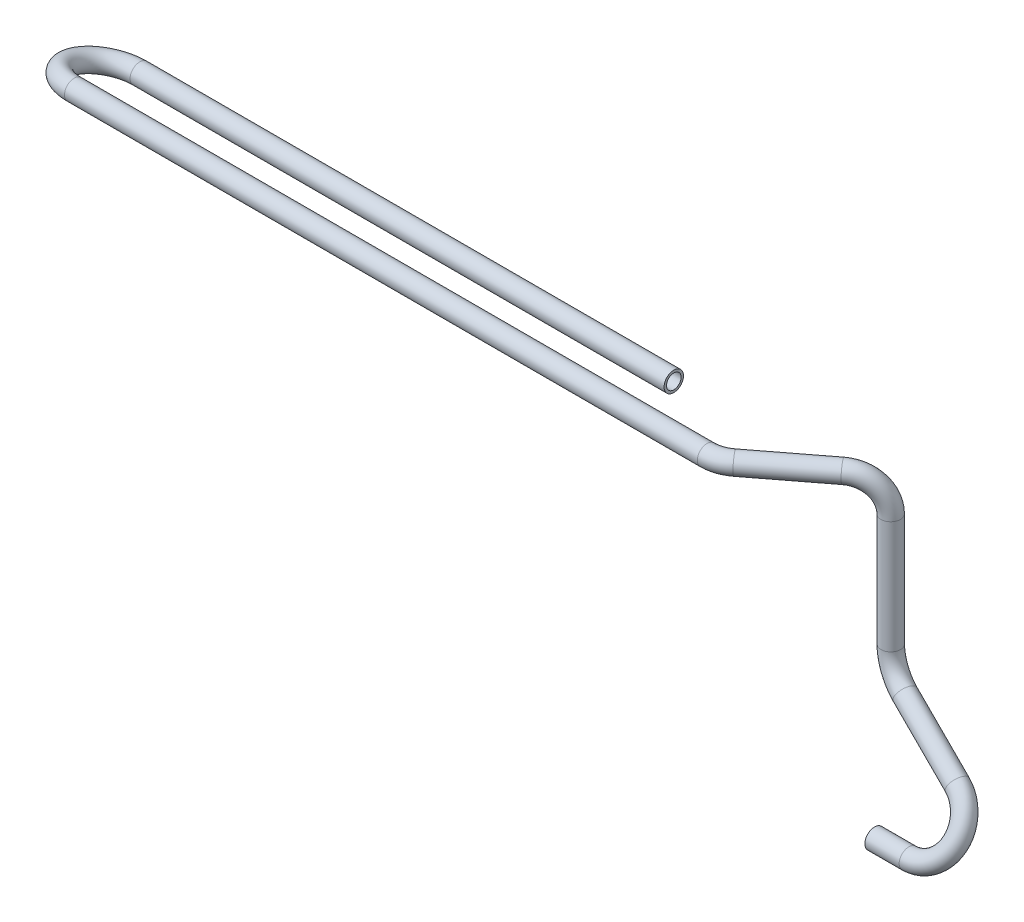
from build123d import *

# Parameters (mm, degrees)
SKETCH1_R   = 6
SKETCH1_R_2 = 4.5


with BuildPart() as part:
    # Sweep1: sweep along a curve in space
    with BuildLine() as sweep1_path:
        Line((0, 0, 0), (21.137511459, 0, 0))
        ThreePointArc((21.137511459, 0, 0), (41.508537571, 13.733128105, -8.010991394), (31.03415803, 34.138080909, -19.91388053))
        Line((-12.988867376, 54.456400328, -31.766233524), (31.03415803, 34.138080909, -19.91388053))
        ThreePointArc((-12.988867376, 54.456400328, -31.766233524), (-21.737931877, 62.19535533, -34.120792385), (-25.013094441, 73.61821862, -35))
        Line((-25.013094441, 73.61821862, -35), (-25.079823104, 143.016028327, -35))
        ThreePointArc((-41.753021103, 164, -22.232683821), (-29.970877633, 157.854907976, -31.261130446), (-25.079823104, 143.016028327, -35))
        Line((-41.753021103, 164, -22.232683821), (-79.446609027, 164, 6.665733587))
        ThreePointArc((-92.223671443, 164, 11), (-85.477576474, 164, 9.886935477), (-79.446609027, 164, 6.665733587))
        Line((-92.223671443, 164, 11), (-482.1, 164, 11))
        ThreePointArc((-482.1, 164, 11), (-503.1, 158.25, -9.197462712), (-482.1, 152.5, -29.394925424))
        Line((-153.1, 152.5, -29.394925424), (-482.1, 152.5, -29.394925424))
    # Sketch1 → Sweep1 (sweep)
    with BuildSketch(Plane(origin=(0, 0, 0), x_dir=(0, 0, -1), z_dir=(1, 0, 0))):
        Circle(SKETCH1_R)
        Circle(SKETCH1_R_2, mode=Mode.SUBTRACT)
    sweep(path=sweep1_path.line)


solid = part.part
